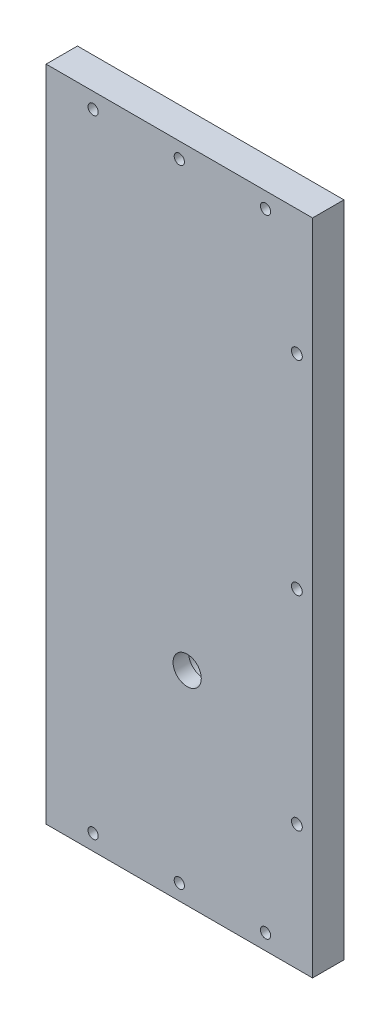
from build123d import *

# Parameters (mm, degrees)
SKETCH1_W                                           = 85
SKETCH1_H                                           = 210
BOSS_EXTRUDE1_DEPTH                                 = 10
CBORE_FOR_4_BINDING_HEAD_MACHINE_SCREW1_D           = 3.4544
CBORE_FOR_4_BINDING_HEAD_MACHINE_SCREW1_CBORE_D     = 6.74624
CBORE_FOR_4_BINDING_HEAD_MACHINE_SCREW1_CBORE_DEPTH = 1.7272
CBORE_FOR_4_BINDING_HEAD_MACHINE_SCREW2_D           = 3.2639
CBORE_FOR_4_BINDING_HEAD_MACHINE_SCREW2_DEPTH       = 10
CBORE_FOR_4_BINDING_HEAD_MACHINE_SCREW2_CBORE_D     = 6.74624
CBORE_FOR_4_BINDING_HEAD_MACHINE_SCREW2_CBORE_DEPTH = 1.7272
SKETCH10_R                                          = 6.35
SKETCH10_R_2                                        = 4.5
CUT_EXTRUDE1_DEPTH                                  = 5
CUT_EXTRUDE3_REACH                                  = 12
SKETCH10_3_R                                        = 4.5
F_4_40_TAPPED_HOLE2_D                               = 2.2606
F_4_40_TAPPED_HOLE2_DEPTH                           = 7.6
F_4_40_TAPPED_HOLE2_TIP                             = 0.679152758


with BuildPart() as part:
    # Sketch1 → Boss-Extrude1 (new body)
    with BuildSketch(Plane.XY):
        with Locations((-115.863171355, -13.158567775)):
            Rectangle(SKETCH1_W, SKETCH1_H)
    extrude(amount=BOSS_EXTRUDE1_DEPTH)

    # CBORE for _4 Binding Head Machine Screw1 (through all)
    with Locations(Plane(origin=(0, 0, 0), x_dir=(-1, 0, 0), z_dir=(0, 0, -1))):
        with Locations((78.363171355, 51.841432225), (78.363171355, -13.158567775), (78.363171355, -78.158567775)):
            CounterBoreHole(CBORE_FOR_4_BINDING_HEAD_MACHINE_SCREW1_D / 2, CBORE_FOR_4_BINDING_HEAD_MACHINE_SCREW1_CBORE_D / 2, CBORE_FOR_4_BINDING_HEAD_MACHINE_SCREW1_CBORE_DEPTH)

    # CBORE for _4 Binding Head Machine Screw2
    with Locations(Plane(origin=(0, 0, 0), x_dir=(-1, 0, 0), z_dir=(0, 0, -1))):
        with Locations((88.363171355, 86.841432225), (115.863171355, 86.841432225), (143.363171355, 86.841432225), (143.363171355, -113.158567775), (115.863171355, -113.158567775), (88.363171355, -113.158567775)):
            CounterBoreHole(CBORE_FOR_4_BINDING_HEAD_MACHINE_SCREW2_D / 2, CBORE_FOR_4_BINDING_HEAD_MACHINE_SCREW2_CBORE_D / 2, CBORE_FOR_4_BINDING_HEAD_MACHINE_SCREW2_CBORE_DEPTH, depth=CBORE_FOR_4_BINDING_HEAD_MACHINE_SCREW2_DEPTH)

    # Sketch10 → Cut-Extrude1 (cut)
    with BuildSketch(Plane(origin=(0, 0, 0), x_dir=(-1, 0, 0), z_dir=(0, 0, -1))):
        with Locations((113.363171355, -53.158567775)):
            Circle(SKETCH10_R)
        with Locations((113.363171355, -53.158567775)):
            Circle(SKETCH10_R_2, mode=Mode.SUBTRACT)
    extrude(amount=-CUT_EXTRUDE1_DEPTH, mode=Mode.SUBTRACT)

    # Sketch10_3 → Cut-Extrude3 (cut, up to next)
    with BuildSketch(Plane(origin=(0, 0, 0), x_dir=(-1, 0, 0), z_dir=(0, 0, -1)), mode=Mode.PRIVATE) as cut_extrude3_sk1:
        with Locations((113.363171355, -53.158567775)):
            Circle(SKETCH10_3_R)
    cut_extrude3_tool1 = extrude(cut_extrude3_sk1.sketch, amount=-CUT_EXTRUDE3_REACH, mode=Mode.PRIVATE) & part.part
    add(cut_extrude3_tool1.solids().sort_by_distance((-113.363171, -53.158568, 0))[0], mode=Mode.SUBTRACT)

    # 4-40 Tapped Hole2
    with Locations(Plane.ZY.offset(158.363171355)):
        with Locations((5, -63.158567775), (5, 36.841432225)):
            Hole(F_4_40_TAPPED_HOLE2_D / 2, depth=F_4_40_TAPPED_HOLE2_DEPTH)
            with Locations((0, 0, -(F_4_40_TAPPED_HOLE2_DEPTH + F_4_40_TAPPED_HOLE2_TIP / 2))):  # 118° drill point
                Cone(0, F_4_40_TAPPED_HOLE2_D / 2, F_4_40_TAPPED_HOLE2_TIP, mode=Mode.SUBTRACT)


solid = part.part
